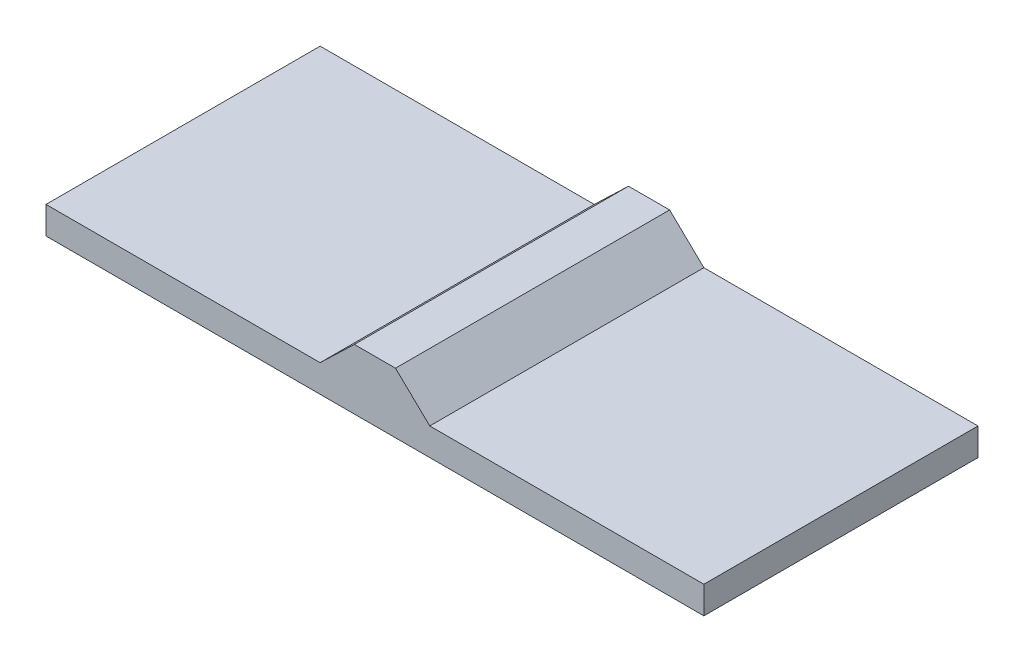
from build123d import *

# Parameters (mm, degrees)
SKETCH1_W           = 3600
SKETCH1_H           = 1500
BOSS_EXTRUDE1_DEPTH = 150
BOSS_EXTRUDE2_DEPTH = 1500


with BuildPart() as part:
    # Sketch1 → Boss-Extrude1 (new body)
    with BuildSketch(Plane(origin=(0, 0, 0), x_dir=(1, 0, 0), z_dir=(0, 1, 0))):
        Rectangle(SKETCH1_W, SKETCH1_H)
    extrude(amount=BOSS_EXTRUDE1_DEPTH)

    # Sketch3 → Boss-Extrude2 (add)
    with BuildSketch(Plane.XY.offset(750)):
        Polygon((300, 150), (-300, 150), (-112.5, 330), (112.5, 330), align=None)
    extrude(amount=-BOSS_EXTRUDE2_DEPTH)


solid = part.part
